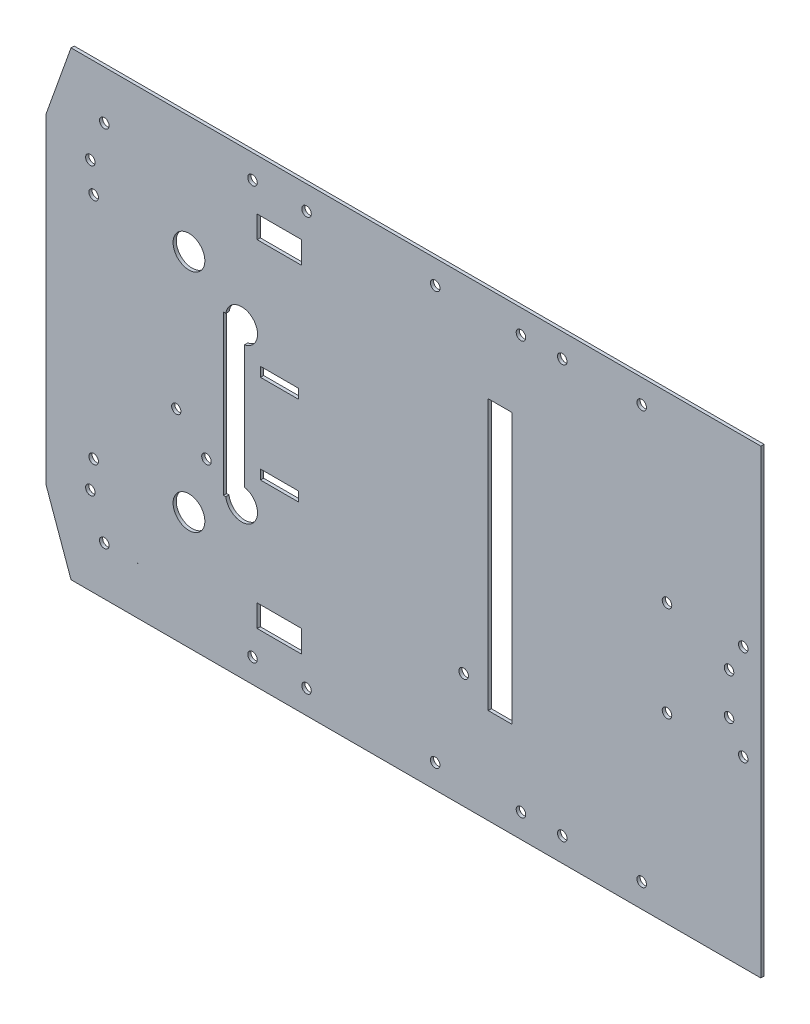
from build123d import *

# Parameters (mm, degrees)
SKETCH1_W            = 150
SKETCH1_H            = 115
BOSS_EXTRUDE1_DEPTH  = 1
SKETCH2_W            = 12
SKETCH2_H            = 3
CUT_EXTRUDE1_DEPTH   = 1
SKETCH6_R            = 1.5
CUT_EXTRUDE8_DEPTH   = 1
SKETCH7_W            = 3
SKETCH7_H            = 12
CUT_EXTRUDE9_DEPTH   = 1
SKETCH8_R            = 1.5
CUT_EXTRUDE10_DEPTH  = 1
SKETCH11_W           = 12
SKETCH11_H           = 7
CUT_EXTRUDE13_DEPTH  = 1
SKETCH13_W           = 12
SKETCH13_H           = 7
CUT_EXTRUDE14_DEPTH  = 1
SKETCH14_W           = 15
SKETCH14_H           = 15
BOSS_EXTRUDE4_DEPTH  = 1
SKETCH16_W           = 15
SKETCH16_H           = 15
BOSS_EXTRUDE6_DEPTH  = 1
SKETCH17_W           = 20
SKETCH17_H           = 115
BOSS_EXTRUDE7_DEPTH  = 1
SKETCH18_W           = 10
SKETCH18_H           = 115.000364416
BOSS_EXTRUDE8_DEPTH  = 1
BOSS_EXTRUDE9_DEPTH  = 1
BOSS_EXTRUDE10_DEPTH = 1
SKETCH21_R           = 1.5
CUT_EXTRUDE15_DEPTH  = 1
SKETCH22_R           = 1.5
CUT_EXTRUDE16_DEPTH  = 1
SKETCH23_R           = 1.5
CUT_EXTRUDE17_DEPTH  = 1
SKETCH24_R           = 1.5
CUT_EXTRUDE18_DEPTH  = 1
SKETCH25_R           = 1.52220731
SKETCH25_R_2         = 1.5
CUT_EXTRUDE19_DEPTH  = 1
SKETCH26_R           = 1.5
CUT_EXTRUDE20_DEPTH  = 1
SKETCH27_W           = 11.454851069
SKETCH27_H           = 7.502285944
CUT_EXTRUDE21_DEPTH  = 1
SKETCH28_W           = 4.81914972
SKETCH28_H           = 7.502285944
BOSS_EXTRUDE11_DEPTH = 1
SKETCH29_W           = 12.611382983
SKETCH29_H           = 7.819372276
CUT_EXTRUDE22_DEPTH  = 1
SKETCH30_W           = 9.50335562
SKETCH30_H           = 7
BOSS_EXTRUDE12_DEPTH = 1
SKETCH31_W           = 13.503593385
SKETCH31_H           = 8.577826874
CUT_EXTRUDE23_DEPTH  = 1
SKETCH32_W           = 1
SKETCH32_H           = 7.819372276
CUT_EXTRUDE24_DEPTH  = 1
SKETCH33_W           = 11.454851069
SKETCH33_H           = 7.502285944
BOSS_EXTRUDE13_DEPTH = 1
SKETCH34_R           = 5
CUT_EXTRUDE25_DEPTH  = 1
SKETCH35_W           = 4.294132012
SKETCH35_H           = 28
CUT_EXTRUDE26_DEPTH  = 1
SKETCH36_R           = 1.5
CUT_EXTRUDE28_DEPTH  = 10
SKETCH37_R           = 5
CUT_EXTRUDE29_DEPTH  = 1
SKETCH38_W           = 50
SKETCH38_H           = 15
BOSS_EXTRUDE14_DEPTH = 1
BOSS_EXTRUDE15_DEPTH = 1
SKETCH40_W           = 30
SKETCH40_H           = 145
BOSS_EXTRUDE16_DEPTH = 1
SKETCH41_W           = 76.030000001
SKETCH41_H           = 15
SKETCH41_W_2         = 76.030243438
BOSS_EXTRUDE17_DEPTH = 1
SKETCH42_R           = 1.5
SKETCH42_R_2         = 1.52220731
SKETCH42_W           = 13.503593385
SKETCH42_H           = 8.577826874
SKETCH42_H_2         = 7.819372276
BOSS_EXTRUDE18_DEPTH = 1
SKETCH43_R           = 1.5
CUT_EXTRUDE30_DEPTH  = 1
SKETCH44_R           = 1.5
SKETCH44_W           = 14
SKETCH44_H           = 7
CUT_EXTRUDE31_DEPTH  = 1
BOSS_EXTRUDE19_DEPTH = 1
SKETCH46_R           = 1.5
CUT_EXTRUDE32_DEPTH  = 1
SKETCH47_W           = 4.294132012
SKETCH47_H           = 28
BOSS_EXTRUDE22_DEPTH = 1
SKETCH48_W           = 0.074133506
SKETCH48_H           = 12
BOSS_EXTRUDE23_DEPTH = 1
SKETCH49_R           = 1.5
SKETCH49_R_2         = 1.45
CUT_EXTRUDE34_DEPTH  = 1
SKETCH50_R           = 1.5
CUT_EXTRUDE35_DEPTH  = 1
SKETCH51_R           = 1.5
BOSS_EXTRUDE24_DEPTH = 1
SKETCH52_R           = 1.5
CUT_EXTRUDE37_DEPTH  = 1
SKETCH53_W           = 6.619650314
SKETCH53_H           = 50
CUT_EXTRUDE38_DEPTH  = 1
SKETCH54_R           = 1.5
BOSS_EXTRUDE25_DEPTH = 1
SKETCH55_R           = 1.5
CUT_EXTRUDE39_DEPTH  = 10
SKETCH58_W           = 7.5
SKETCH58_H           = 85
CUT_EXTRUDE40_DEPTH  = 1


with BuildPart() as part:
    # Sketch1 → Boss-Extrude1 (new body)
    with BuildSketch(Plane.XY):
        with Locations((75, -57.5)):
            Rectangle(SKETCH1_W, SKETCH1_H)
    extrude(amount=BOSS_EXTRUDE1_DEPTH)

    # Sketch2 → Cut-Extrude1 (cut)
    with BuildSketch(Plane.XY.offset(1)):
        with Locations((28.5, -43.5)):
            Rectangle(SKETCH2_W, SKETCH2_H)
        with Locations((28.5, -71.5)):
            Rectangle(SKETCH2_W, SKETCH2_H)
    extrude(amount=-CUT_EXTRUDE1_DEPTH, mode=Mode.SUBTRACT)

    # Sketch6 → Cut-Extrude8 (cut)
    with BuildSketch(Plane.XY.offset(1)):
        with Locations((38.660903006, -17.425022317)):
            Circle(SKETCH6_R)
        with Locations((86.463008881, -93.763435153)):
            Circle(SKETCH6_R)
    extrude(amount=-CUT_EXTRUDE8_DEPTH, mode=Mode.SUBTRACT)

    # Sketch7 → Cut-Extrude9 (cut)
    with BuildSketch(Plane.XY.offset(1)):
        with Locations((7.22120379, -57.5)):
            Rectangle(SKETCH7_W, SKETCH7_H)
    extrude(amount=-CUT_EXTRUDE9_DEPTH, mode=Mode.SUBTRACT)

    # Sketch8 → Cut-Extrude10 (cut)
    with BuildSketch(Plane.XY.offset(1)):
        with Locations((17, -5)):
            Circle(SKETCH8_R)
        with Locations((38.5, -5)):
            Circle(SKETCH8_R)
        with Locations((17, -110)):
            Circle(SKETCH8_R)
        with Locations((38.5, -110)):
            Circle(SKETCH8_R)
    extrude(amount=-CUT_EXTRUDE10_DEPTH, mode=Mode.SUBTRACT)

    # Sketch11 → Cut-Extrude13 (cut)
    with BuildSketch(Plane.XY.offset(1)):
        with Locations((28, -19.1)):
            Rectangle(SKETCH11_W, SKETCH11_H)
    extrude(amount=-CUT_EXTRUDE13_DEPTH, mode=Mode.SUBTRACT)

    # Sketch13 → Cut-Extrude14 (cut)
    with BuildSketch(Plane.XY.offset(1)):
        with Locations((28, -95.9)):
            Rectangle(SKETCH13_W, SKETCH13_H)
    extrude(amount=-CUT_EXTRUDE14_DEPTH, mode=Mode.SUBTRACT)

    # Sketch14 → Boss-Extrude4 (add)
    with BuildSketch(Plane.XY.offset(1)):
        with Locations((142.5, 7.5)):
            Rectangle(SKETCH14_W, SKETCH14_H)
        with Locations((142.5, -122.5)):
            Rectangle(SKETCH14_W, SKETCH14_H)
    extrude(amount=-BOSS_EXTRUDE4_DEPTH)

    # Sketch16 → Boss-Extrude6 (add)
    with BuildSketch(Plane.XY.offset(1)):
        with Locations((77.5, 7.5)):
            Rectangle(SKETCH16_W, SKETCH16_H)
        with Locations((77.5, -122.5)):
            Rectangle(SKETCH16_W, SKETCH16_H)
    extrude(amount=-BOSS_EXTRUDE6_DEPTH)

    # Sketch17 → Boss-Extrude7 (add)
    with BuildSketch(Plane.XY.offset(1)):
        with Locations((-10, -57.5)):
            Rectangle(SKETCH17_W, SKETCH17_H)
    extrude(amount=-BOSS_EXTRUDE7_DEPTH)

    # Sketch18 → Boss-Extrude8 (add)
    with BuildSketch(Plane(origin=(0, 0, 0), x_dir=(-1, 0, 0), z_dir=(0, 0, -1))):
        with Locations((25, -57.500182208)):
            Rectangle(SKETCH18_W, SKETCH18_H)
    extrude(amount=-BOSS_EXTRUDE8_DEPTH)

    # Sketch19 → Boss-Extrude9 (add)
    with BuildSketch(Plane.XY.offset(1)):
        Polygon((-30, 0), (-6.030243438, 10.990373671), (-6.030243438, 0), align=None)
    extrude(amount=-BOSS_EXTRUDE9_DEPTH)

    # Sketch20 → Boss-Extrude10 (add)
    with BuildSketch(Plane.XY.offset(1)):
        Polygon((-30, -115.000364416), (-6.030000001, -125.990153925), (-6.030000001, -115.000153925), align=None)
    extrude(amount=-BOSS_EXTRUDE10_DEPTH)

    # Sketch21 → Cut-Extrude15 (cut)
    with BuildSketch(Plane.XY.offset(1)):
        with Locations((-20.843675083, -21.50019062)):
            Circle(SKETCH21_R)
        with Locations((-20.843675083, -93.50019062)):
            Circle(SKETCH21_R)
    extrude(amount=-CUT_EXTRUDE15_DEPTH, mode=Mode.SUBTRACT)

    # Sketch22 → Cut-Extrude16 (cut)
    with BuildSketch(Plane.XY.offset(1)):
        with Locations((-13.039930758, -21.607097789)):
            Circle(SKETCH22_R)
        with Locations((-13.039930758, -93.607097789)):
            Circle(SKETCH22_R)
    extrude(amount=-CUT_EXTRUDE16_DEPTH, mode=Mode.SUBTRACT)

    # Sketch23 → Cut-Extrude17 (cut)
    with BuildSketch(Plane.XY.offset(1)):
        with Locations((142.5, -122.5)):
            Circle(SKETCH23_R)
        with Locations((77.5, -122.5)):
            Circle(SKETCH23_R)
        with Locations((142.5, 7.5)):
            Circle(SKETCH23_R)
        with Locations((77.5, 7.5)):
            Circle(SKETCH23_R)
    extrude(amount=-CUT_EXTRUDE17_DEPTH, mode=Mode.SUBTRACT)

    # Sketch24 → Cut-Extrude18 (cut)
    with BuildSketch(Plane.XY.offset(1)):
        with Locations((134.5, -41.5)):
            Circle(SKETCH24_R)
        with Locations((134.5, -73.5)):
            Circle(SKETCH24_R)
        with Locations((109.5, -41.5)):
            Circle(SKETCH24_R)
        with Locations((109.5, -73.5)):
            Circle(SKETCH24_R)
    extrude(amount=-CUT_EXTRUDE18_DEPTH, mode=Mode.SUBTRACT)

    # Sketch25 → Cut-Extrude19 (cut)
    with BuildSketch(Plane.XY.offset(1)):
        with Locations((28.5, -5)):
            Circle(SKETCH25_R)
        with Locations((7, -5)):
            Circle(SKETCH25_R_2)
    extrude(amount=-CUT_EXTRUDE19_DEPTH, mode=Mode.SUBTRACT)

    # Sketch26 → Cut-Extrude20 (cut)
    with BuildSketch(Plane.XY.offset(1)):
        with Locations((28.500000001, -110.000105781)):
            Circle(SKETCH26_R)
        with Locations((7.000000001, -110.000105781)):
            Circle(SKETCH26_R)
    extrude(amount=-CUT_EXTRUDE20_DEPTH, mode=Mode.SUBTRACT)

    # Sketch27 → Cut-Extrude21 (cut)
    with BuildSketch(Plane.XY.offset(1)):
        with Locations((32.546575255, -96.151142972)):
            Rectangle(SKETCH27_W, SKETCH27_H)
    extrude(amount=-CUT_EXTRUDE21_DEPTH, mode=Mode.SUBTRACT)

    # Sketch28 → Boss-Extrude11 (add)
    with BuildSketch(Plane.XY.offset(1)):
        with Locations((24.40957486, -96.151142972)):
            Rectangle(SKETCH28_W, SKETCH28_H)
    extrude(amount=-BOSS_EXTRUDE11_DEPTH)

    # Sketch29 → Cut-Extrude22 (cut)
    with BuildSketch(Plane.XY.offset(1)):
        with Locations((18.298742487, -18.690313862)):
            Rectangle(SKETCH29_W, SKETCH29_H)
    extrude(amount=-CUT_EXTRUDE22_DEPTH, mode=Mode.SUBTRACT)

    # Sketch30 → Boss-Extrude12 (add)
    with BuildSketch(Plane.XY.offset(1)):
        with Locations((29.24832219, -19.1)):
            Rectangle(SKETCH30_W, SKETCH30_H)
    extrude(amount=-BOSS_EXTRUDE12_DEPTH)

    # Sketch31 → Cut-Extrude23 (cut)
    with BuildSketch(Plane.XY.offset(1)):
        with Locations((17.744847688, -96.688913437)):
            Rectangle(SKETCH31_W, SKETCH31_H)
    extrude(amount=-CUT_EXTRUDE23_DEPTH, mode=Mode.SUBTRACT)

    # Sketch32 → Cut-Extrude24 (cut)
    with BuildSketch(Plane.XY.offset(1)):
        with Locations((11.493050995, -18.690313862)):
            Rectangle(SKETCH32_W, SKETCH32_H)
    extrude(amount=-CUT_EXTRUDE24_DEPTH, mode=Mode.SUBTRACT)

    # Sketch33 → Boss-Extrude13 (add)
    with BuildSketch(Plane.XY.offset(1)):
        with Locations((32.546575255, -96.151142972)):
            Rectangle(SKETCH33_W, SKETCH33_H)
    extrude(amount=-BOSS_EXTRUDE13_DEPTH)

    # Sketch34 → Cut-Extrude25 (cut)
    with BuildSketch(Plane(origin=(0, 0, 0), x_dir=(-1, 0, 0), z_dir=(0, 0, -1))):
        with Locations((-0.000361951, -93.000178425)):
            Circle(SKETCH34_R)
        with Locations((-0.000180975, -22)):
            Circle(SKETCH34_R)
    extrude(amount=-CUT_EXTRUDE25_DEPTH, mode=Mode.SUBTRACT)

    # Sketch35 → Cut-Extrude26 (cut)
    with BuildSketch(Plane(origin=(0, 0, 0), x_dir=(-1, 0, 0), z_dir=(0, 0, -1))):
        with Locations((-7.942403302, -57.5)):
            Rectangle(SKETCH35_W, SKETCH35_H)
    extrude(amount=-CUT_EXTRUDE26_DEPTH, mode=Mode.SUBTRACT)

    # Sketch36 → Cut-Extrude28 (cut)
    with BuildSketch(Plane(origin=(0, 0, 0), x_dir=(-1, 0, 0), z_dir=(0, 0, -1))):
        with Locations((14, -105.990153925)):
            Circle(SKETCH36_R)
        with Locations((14, -9.009626329)):
            Circle(SKETCH36_R)
    extrude(amount=-CUT_EXTRUDE28_DEPTH, mode=Mode.SUBTRACT)

    # Sketch37 → Cut-Extrude29 (cut)
    with BuildSketch(Plane(origin=(0, 0, 0), x_dir=(-1, 0, 0), z_dir=(0, 0, -1))):
        with Locations((-16.579768875, -82.4)):
            Circle(SKETCH37_R)
        with Locations((-16.579768875, -33.716640554)):
            Circle(SKETCH37_R)
    extrude(amount=-CUT_EXTRUDE29_DEPTH, mode=Mode.SUBTRACT)

    # Sketch38 → Boss-Extrude14 (add)
    with BuildSketch(Plane(origin=(0, 0, 0), x_dir=(-1, 0, 0), z_dir=(0, 0, -1))):
        with Locations((-110, -122.5)):
            Rectangle(SKETCH38_W, SKETCH38_H)
        with Locations((-110, 7.5)):
            Rectangle(SKETCH38_W, SKETCH38_H)
    extrude(amount=-BOSS_EXTRUDE14_DEPTH)

    # Sketch39 → Boss-Extrude15 (add)
    with BuildSketch(Plane.XY.offset(1)):
        Polygon((-30, 0), (-45, -6.994614872), (-45, -108.005749543), (-30, -115.000364416), align=None)
    extrude(amount=-BOSS_EXTRUDE15_DEPTH)

    # Sketch40 → Boss-Extrude16 (add)
    with BuildSketch(Plane.XY.offset(1)):
        with Locations((165, -57.5)):
            Rectangle(SKETCH40_W, SKETCH40_H)
    extrude(amount=-BOSS_EXTRUDE16_DEPTH)

    # Sketch41 → Boss-Extrude17 (add)
    with BuildSketch(Plane(origin=(0, 0, 0), x_dir=(-1, 0, 0), z_dir=(0, 0, -1))):
        with Locations((-31.985, -122.5)):
            Rectangle(SKETCH41_W, SKETCH41_H)
        with Locations((-31.984878281, 7.5)):
            Rectangle(SKETCH41_W_2, SKETCH41_H)
    extrude(amount=-BOSS_EXTRUDE17_DEPTH)

    # Sketch42 → Boss-Extrude18 (add)
    with BuildSketch(Plane(origin=(0, 0, 0), x_dir=(-1, 0, 0), z_dir=(0, 0, -1))):
        with Locations((-38.5, -110)):
            Circle(SKETCH42_R)
        with Locations((-28.500000001, -110.000105781)):
            Circle(SKETCH42_R)
        with Locations((-17, -110)):
            Circle(SKETCH42_R)
        with Locations((-7.000000001, -110.000105781)):
            Circle(SKETCH42_R)
        with Locations((14, -105.990153925)):
            Circle(SKETCH42_R)
        with Locations((13.039930758, -93.607097789)):
            Circle(SKETCH42_R)
        with Locations((20.843675083, -93.50019062)):
            Circle(SKETCH42_R)
        with Locations((-38.660903006, -17.425022317)):
            Circle(SKETCH42_R)
        with Locations((-38.5, -5)):
            Circle(SKETCH42_R)
        with Locations((-28.5, -5)):
            Circle(SKETCH42_R_2)
        with Locations((-17, -5)):
            Circle(SKETCH42_R)
        with Locations((-7, -5)):
            Circle(SKETCH42_R)
        with Locations((14, -9.009626329)):
            Circle(SKETCH42_R)
        with Locations((13.039930758, -21.607097789)):
            Circle(SKETCH42_R)
        with Locations((20.843675083, -21.50019062)):
            Circle(SKETCH42_R)
        with Locations((-17.744847688, -96.688913437)):
            Rectangle(SKETCH42_W, SKETCH42_H)
        with Locations((-17.744847688, -18.690313862)):
            Rectangle(SKETCH42_W, SKETCH42_H_2)
    extrude(amount=-BOSS_EXTRUDE18_DEPTH)

    # Sketch43 → Cut-Extrude30 (cut)
    with BuildSketch(Plane.XY.offset(1)):
        with Locations((-29.999819025, -21.5)):
            Circle(SKETCH43_R)
        with Locations((-29.999819025, -93.5)):
            Circle(SKETCH43_R)
    extrude(amount=-CUT_EXTRUDE30_DEPTH, mode=Mode.SUBTRACT)

    # Sketch44 → Cut-Extrude31 (cut)
    with BuildSketch(Plane.XY.offset(1)):
        with Locations((20.000180975, 7.5)):
            Circle(SKETCH44_R)
        with Locations((20.000180975, -122.5)):
            Circle(SKETCH44_R)
        with Locations((37.000180975, 7.5)):
            Circle(SKETCH44_R)
        with Locations((37.000180975, -122.5)):
            Circle(SKETCH44_R)
        with Locations((28.469756562, -4.5)):
            Rectangle(SKETCH44_W, SKETCH44_H)
        with Locations((28.469756562, -110.5)):
            Rectangle(SKETCH44_W, SKETCH44_H)
    extrude(amount=-CUT_EXTRUDE31_DEPTH, mode=Mode.SUBTRACT)

    # Sketch45 → Boss-Extrude19 (add)
    with BuildSketch(Plane(origin=(0, 0, 0), x_dir=(-1, 0, 0), z_dir=(0, 0, -1))):
        Polygon((6.030000001, -130), (37.128465769, -130), (45, -108.005749543), (6.030000001, -125.990153925), align=None)
        Polygon((6.030243438, 15), (6.030243438, 10.990373671), (45, -6.994614872), (37.128465769, 15), align=None)
    extrude(amount=-BOSS_EXTRUDE19_DEPTH)

    # Sketch46 → Cut-Extrude32 (cut)
    with BuildSketch(Plane.XY.offset(1)):
        with Locations((170, -51)):
            Circle(SKETCH46_R)
        with Locations((170, -64)):
            Circle(SKETCH46_R)
        with Locations((117.5, 7.5)):
            Circle(SKETCH46_R)
        with Locations((104.5, 7.5)):
            Circle(SKETCH46_R)
        with Locations((117.5, -122.5)):
            Circle(SKETCH46_R)
        with Locations((104.5, -122.5)):
            Circle(SKETCH46_R)
        with Locations((-20, 7.5)):
            Circle(SKETCH46_R)
        with Locations((-7, 7.5)):
            Circle(SKETCH46_R)
        with Locations((-17, -122.5)):
            Circle(SKETCH46_R)
        with Locations((-30, -122.5)):
            Circle(SKETCH46_R)
    extrude(amount=-CUT_EXTRUDE32_DEPTH, mode=Mode.SUBTRACT)

    # Sketch47 → Boss-Extrude22 (add)
    with BuildSketch(Plane.XY.offset(1)):
        with Locations((7.942403302, -57.5)):
            Rectangle(SKETCH47_W, SKETCH47_H)
    extrude(amount=-BOSS_EXTRUDE22_DEPTH)

    # Sketch48 → Boss-Extrude23 (add)
    with BuildSketch(Plane.XY.offset(1)):
        with Locations((5.758270543, -57.5)):
            Rectangle(SKETCH48_W, SKETCH48_H)
    extrude(amount=-BOSS_EXTRUDE23_DEPTH)

    # Sketch49 → Cut-Extrude34 (cut)
    with BuildSketch(Plane.XY.offset(1)):
        with Locations((5.5, -75.78)):
            Circle(SKETCH49_R)
        with Locations((15, -66.84)):
            Circle(SKETCH49_R_2)
        with Locations((-4, -66.84)):
            Circle(SKETCH49_R_2)
    extrude(amount=-CUT_EXTRUDE34_DEPTH, mode=Mode.SUBTRACT)

    # Sketch50 → Cut-Extrude35 (cut)
    with BuildSketch(Plane.XY.offset(1)):
        with Locations((-19.703771228, -109.51)):
            Circle(SKETCH50_R)
        with Locations((-19.703757021, -5.49)):
            Circle(SKETCH50_R)
    extrude(amount=-CUT_EXTRUDE35_DEPTH, mode=Mode.SUBTRACT)

    # Sketch51 → Boss-Extrude24 (add)
    with BuildSketch(Plane.XY.offset(1)):
        with Locations((-20, 7.5)):
            Circle(SKETCH51_R)
        with Locations((-7, 7.5)):
            Circle(SKETCH51_R)
        with Locations((-19.703757021, -5.49)):
            Circle(SKETCH51_R)
        with Locations((-19.703771228, -109.51)):
            Circle(SKETCH51_R)
        with Locations((-17, -122.5)):
            Circle(SKETCH51_R)
        with Locations((-30, -122.5)):
            Circle(SKETCH51_R)
    extrude(amount=-BOSS_EXTRUDE24_DEPTH)

    # Sketch52 → Cut-Extrude37 (cut)
    with BuildSketch(Plane.XY.offset(1)):
        with Locations((-26.658258628, -0.260419418)):
            Circle(SKETCH52_R)
        with Locations((-31.038682734, -12.500185946)):
            Circle(SKETCH52_R)
        with Locations((-26.658194291, -114.739929448)):
            Circle(SKETCH52_R)
        with Locations((-31.038682734, -102.500185946)):
            Circle(SKETCH52_R)
    extrude(amount=-CUT_EXTRUDE37_DEPTH, mode=Mode.SUBTRACT)

    # Sketch53 → Cut-Extrude38 (cut)
    with BuildSketch(Plane.XY.offset(1)):
        with Locations((14.190174843, -58)):
            Rectangle(SKETCH53_W, SKETCH53_H)
    extrude(amount=-CUT_EXTRUDE38_DEPTH, mode=Mode.SUBTRACT)

    # Sketch54 → Boss-Extrude25 (add)
    with BuildSketch(Plane.XY.offset(1)):
        with Locations((109.5, -41.5)):
            Circle(SKETCH54_R)
        with Locations((109.5, -73.5)):
            Circle(SKETCH54_R)
        with Locations((134.5, -73.5)):
            Circle(SKETCH54_R)
        with Locations((134.5, -41.5)):
            Circle(SKETCH54_R)
    extrude(amount=-BOSS_EXTRUDE25_DEPTH)

    # Sketch55 → Cut-Extrude39 (cut)
    with BuildSketch(Plane.XY.offset(1)):
        with Locations((174.469756562, -42.5)):
            Circle(SKETCH55_R)
        with Locations((174.469756562, -72.5)):
            Circle(SKETCH55_R)
        with Locations((150.469756562, -42.5)):
            Circle(SKETCH55_R)
        with Locations((150.469756562, -72.5)):
            Circle(SKETCH55_R)
    extrude(amount=-CUT_EXTRUDE39_DEPTH, mode=Mode.SUBTRACT)

    # Sketch58 → Cut-Extrude40 (cut)
    with BuildSketch(Plane.XY.offset(1)):
        with Locations((97.916866662, -57.5)):
            Rectangle(SKETCH58_W, SKETCH58_H)
    extrude(amount=-CUT_EXTRUDE40_DEPTH, mode=Mode.SUBTRACT)


solid = part.part
